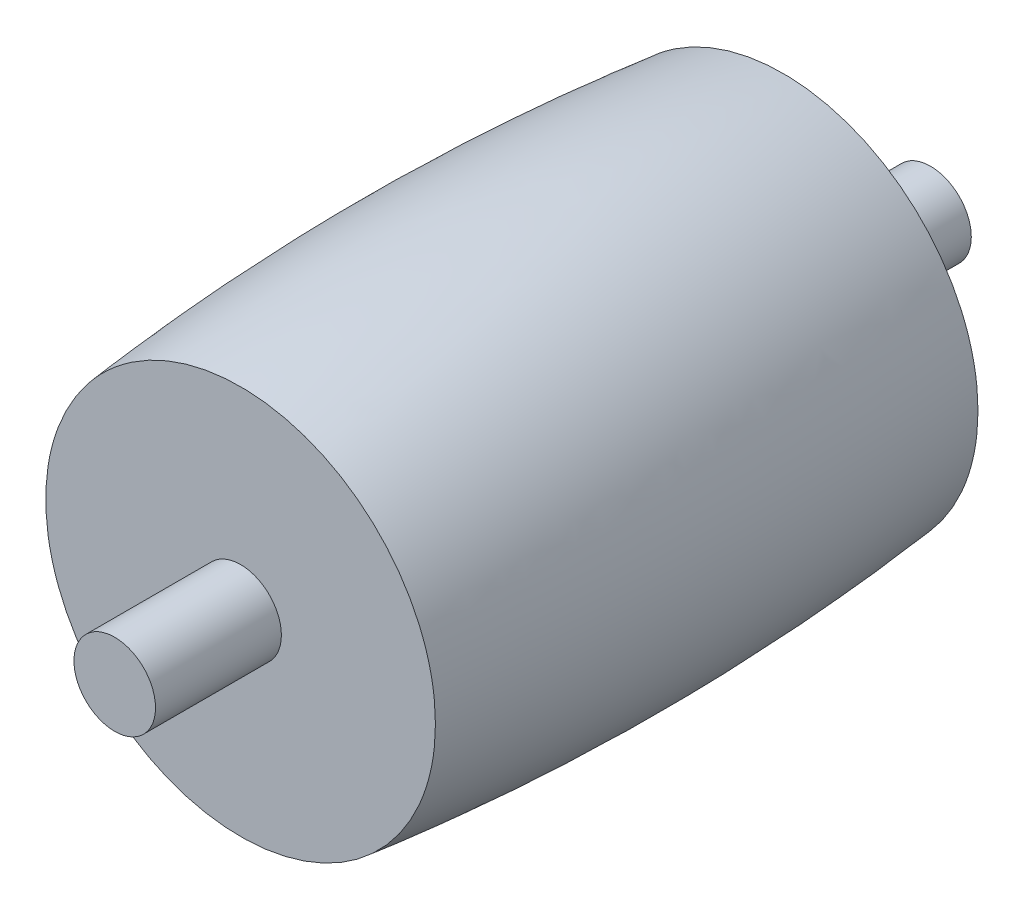
from build123d import *

# Parameters (mm, degrees)
SKETCH_1_R      = 1
EXTRUDE_1_DEPTH = 20


with BuildPart() as part:
    # 草图1 → 凸台-拉伸1 (new body)
    with BuildSketch(Plane.XY):
        Circle(SKETCH_1_R)
    extrude(amount=EXTRUDE_1_DEPTH)

    # 扫描2: sweep along a path in 草图3
    with BuildLine(Plane.XY.offset(10)) as sweep_2_path:
        CenterArc((0, 0), 0.751629147, 0, 360)
    # 草图2 → 扫描2 (sweep)
    with BuildSketch(Plane(origin=(0, 0, 0), x_dir=(1, 0, 0), z_dir=(0, 1, 0))):
        with BuildLine():
            Line((0, -3.612773255), (4.77690428, -3.612773255))
            add(Edge.make_bspline(
                [(4.77690428, -3.612773255), (5.505867442, -10.261978207), (4.77690428, -16.914339916)],
                knots=[0, 0, 0, 1, 1, 1], degree=2))
            Line((4.77690428, -16.914339916), (0, -16.914339916))
            Line((0, -16.914339916), (0, -3.612773255))
        make_face()
    sweep(path=sweep_2_path.line)


solid = part.part
